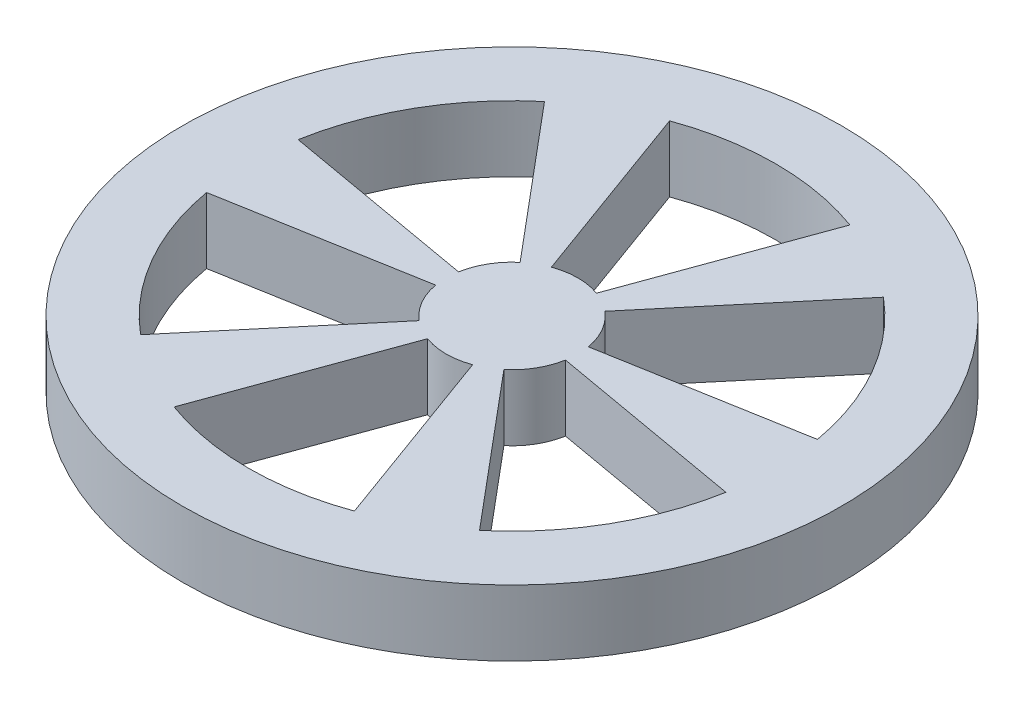
from build123d import *

# Parameters (mm, degrees)
SKETCH_1_R      = 50
EXTRUDE_1_DEPTH = 10


with BuildPart() as part:
    # ｽｹｯﾁ1 → ﾎﾞｽ - 押し出し1 (new body)
    with BuildSketch(Plane(origin=(0, 0, 0), x_dir=(1, 0, 0), z_dir=(0, 1, 0))):
        Circle(SKETCH_1_R)
        with BuildLine():
            Line((-3.420201433, 9.396926208), (-13.680805733, 37.587704831))
            ThreePointArc((-13.680805733, 37.587704831), (0, 40), (13.680805733, 37.587704831))
            Line((13.680805733, 37.587704831), (3.420201433, 9.396926208))
            ThreePointArc((3.420201433, 9.396926208), (0, 10), (-3.420201433, 9.396926208))
        make_face(mode=Mode.SUBTRACT)
        with BuildLine():
            Line((6.428376097, 7.661310457), (25.712004387, 30.64264375))
            ThreePointArc((25.712004387, 30.64264375), (34.641516151, 20.000866025), (39.39281012, 6.946793132))
            Line((39.39281012, 6.946793132), (9.84857753, 1.737347802))
            ThreePointArc((9.84857753, 1.737347802), (8.660754038, 5.000866025), (6.428376097, 7.661310457))
        make_face(mode=Mode.SUBTRACT)
        with BuildLine():
            Line((9.84957753, -1.735615751), (39.39381012, -6.945061081))
            ThreePointArc((39.39381012, -6.945061081), (34.642516151, -19.999133975), (25.713004387, -30.640911699))
            Line((25.713004387, -30.640911699), (6.429376097, -7.659578406))
            ThreePointArc((6.429376097, -7.659578406), (8.661754038, -4.999133975), (9.84957753, -1.735615751))
        make_face(mode=Mode.SUBTRACT)
        with BuildLine():
            Line((3.422201433, -9.396926208), (13.682805733, -37.587704831))
            ThreePointArc((13.682805733, -37.587704831), (0.002, -40), (-13.678805733, -37.587704831))
            Line((-13.678805733, -37.587704831), (-3.418201433, -9.396926208))
            ThreePointArc((-3.418201433, -9.396926208), (0.002, -10), (3.422201433, -9.396926208))
        make_face(mode=Mode.SUBTRACT)
        with BuildLine():
            Line((-6.426376097, -7.661310457), (-25.710004387, -30.64264375))
            ThreePointArc((-25.710004387, -30.64264375), (-34.639516151, -20.000866025), (-39.39081012, -6.946793132))
            Line((-39.39081012, -6.946793132), (-9.84657753, -1.737347802))
            ThreePointArc((-9.84657753, -1.737347802), (-8.658754038, -5.000866025), (-6.426376097, -7.661310457))
        make_face(mode=Mode.SUBTRACT)
        with BuildLine():
            Line((-9.84757753, 1.735615751), (-39.39181012, 6.945061081))
            ThreePointArc((-39.39181012, 6.945061081), (-34.640516151, 19.999133975), (-25.711004387, 30.640911699))
            Line((-25.711004387, 30.640911699), (-6.427376097, 7.659578406))
            ThreePointArc((-6.427376097, 7.659578406), (-8.659754038, 4.999133975), (-9.84757753, 1.735615751))
        make_face(mode=Mode.SUBTRACT)
    extrude(amount=EXTRUDE_1_DEPTH)


solid = part.part
